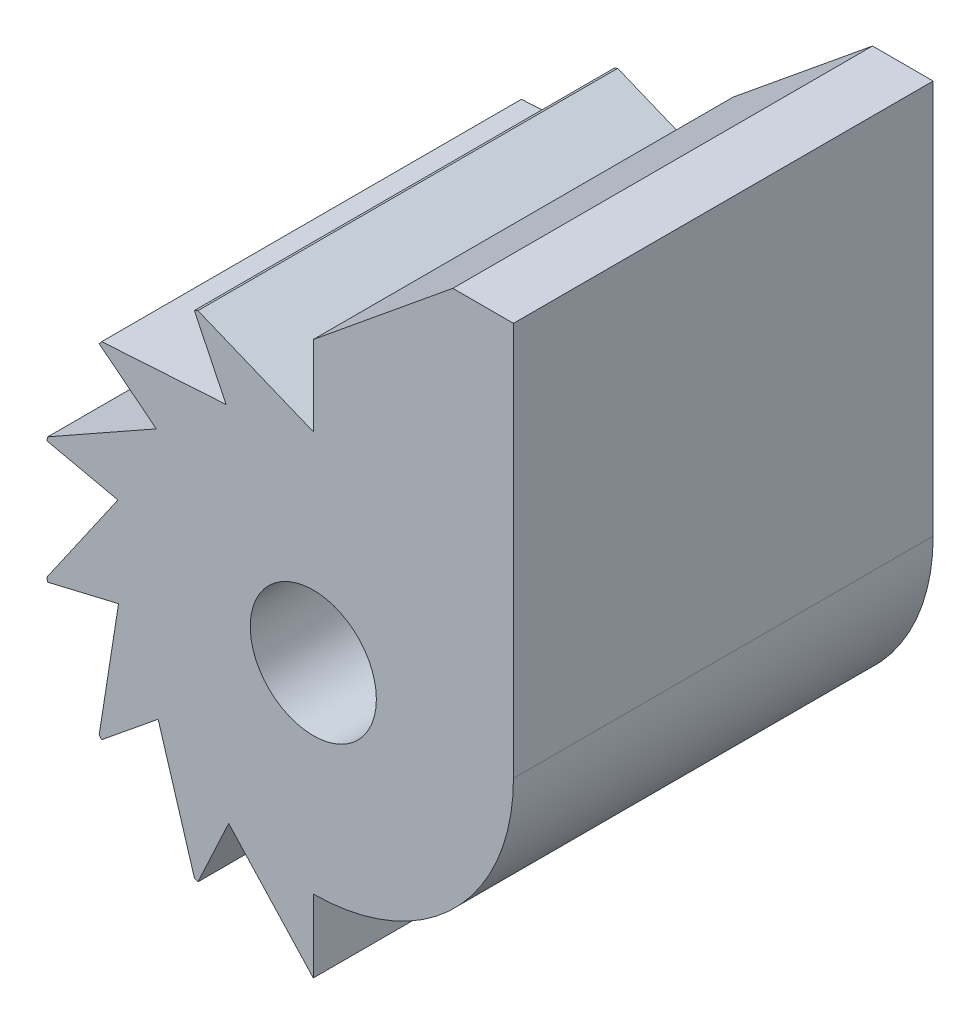
from build123d import *

# Parameters (mm, degrees)
SKETCH1_R           = 3.302
BOSS_EXTRUDE1_DEPTH = 21.971
CUT_EXTRUDE1_DEPTH  = 22.971
CUT_EXTRUDE2_DEPTH  = 22.971


with BuildPart() as part:
    # Sketch1 → Boss-Extrude1 (new body)
    with BuildSketch(Plane.XY):
        with BuildLine():
            ThreePointArc((0, -10.4775), (7.4087113, -7.4087113), (10.4775, 0))
            Line((10.4775, 0), (10.4775, 20.629972189))
            Line((10.4775, 20.629972189), (7.3025, 20.629972189))
            Line((7.3025, 20.629972189), (-0.463735424, 14.279972189))
            ThreePointArc((-0.463735424, 14.279972189), (-14.285617923, -0.23189826), (0, -14.2875))
            Line((0, -14.2875), (0, -10.4775))
        make_face()
        Circle(SKETCH1_R, mode=Mode.SUBTRACT)
    extrude(amount=BOSS_EXTRUDE1_DEPTH)

    # Sketch3 → Cut-Extrude1 (cut, through all)
    with BuildSketch(Plane.XY.offset(21.971)):
        with BuildLine():
            Line((0, -14.2875), (-4.427982837, -9.495839839))
            Line((-4.427982837, -9.495839839), (-6.038158415, -12.948872507))
            ThreePointArc((-6.038158415, -12.948872507), (-3.092380984, -13.948829202), (0, -14.2875))
        make_face()
        with BuildLine():
            Line((-8.12333208, -6.617362176), (-11.077271018, -9.023675694))
            ThreePointArc((-11.077271018, -9.023675694), (-8.861614581, -11.207338813), (-6.225846847, -12.859684572))
            Line((-6.225846847, -12.859684572), (-8.12333208, -6.617362176))
        make_face()
        with BuildLine():
            Line((-10.195077632, -2.416277786), (-13.902378588, -3.294924253))
            ThreePointArc((-13.902378588, -3.294924253), (-12.859684572, -6.225846847), (-11.207338813, -8.861614581))
            Line((-11.207338813, -8.861614581), (-10.195077632, -2.416277786))
        make_face()
        with BuildLine():
            Line((-10.229141415, 2.267746055), (-13.948829202, 3.092380984))
            ThreePointArc((-13.948829202, 3.092380984), (-14.2875, 0), (-13.948829202, -3.092380984))
            Line((-13.948829202, -3.092380984), (-10.229141415, 2.267746055))
        make_face()
        with BuildLine():
            Line((-8.218715129, 6.49851736), (-11.207338813, 8.861614581))
            ThreePointArc((-11.207338813, 8.861614581), (-12.859684572, 6.225846847), (-13.902378588, 3.294924253))
            Line((-13.902378588, 3.294924253), (-8.218715129, 6.49851736))
        make_face()
        with BuildLine():
            Line((-4.565621021, 9.430435353), (-6.225846847, 12.859684572))
            ThreePointArc((-6.225846847, 12.859684572), (-8.861614581, 11.207338813), (-11.077271018, 9.023675694))
            Line((-11.077271018, 9.023675694), (-4.565621021, 9.430435353))
        make_face()
        with BuildLine():
            Line((0, 10.4775), (0, 14.2875))
            ThreePointArc((0, 14.2875), (-3.092380984, 13.948829202), (-6.038158415, 12.948872507))
            Line((-6.038158415, 12.948872507), (0, 10.4775))
        make_face()
    extrude(amount=-CUT_EXTRUDE1_DEPTH, mode=Mode.SUBTRACT)

    # Sketch4 → Cut-Extrude2 (cut, through all)
    with BuildSketch(Plane.XY.offset(21.971)):
        Polygon((-0.463735424, 14.279972189), (0, 14.2875), (0, 14.659141732), align=None)
    extrude(amount=-CUT_EXTRUDE2_DEPTH, mode=Mode.SUBTRACT)


solid = part.part
